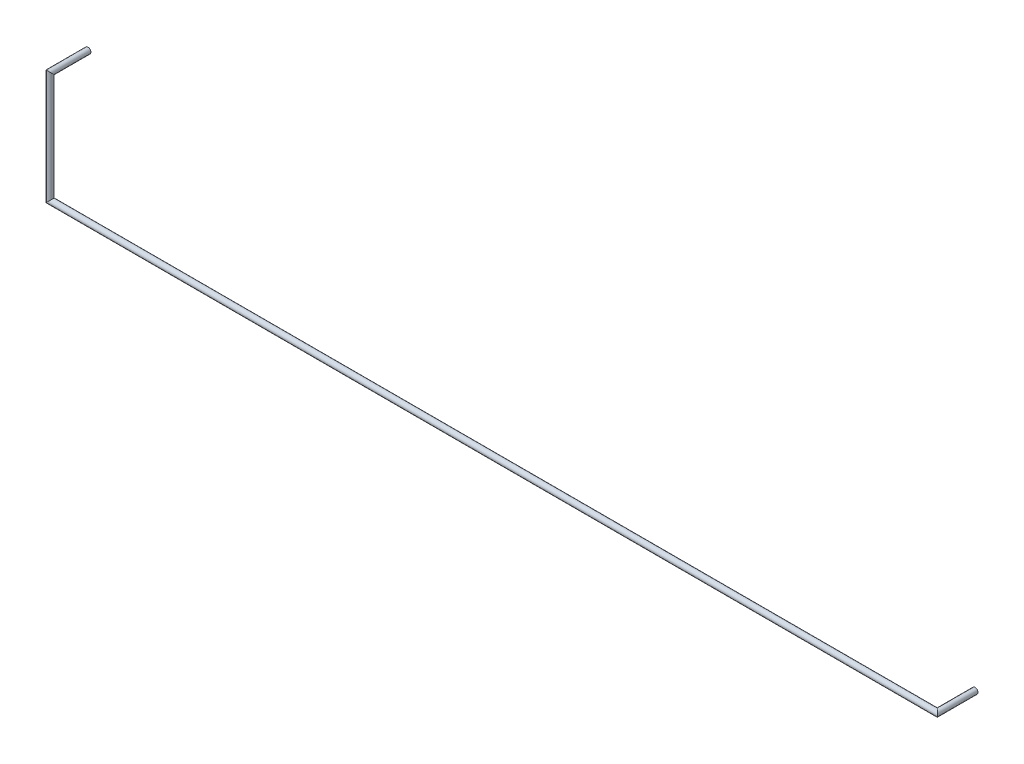
from build123d import *

# Parameters (mm, degrees)
SWEEP1_PROFILE_R = 0.2


with BuildPart() as part:
    # Sweep1: sweep along a curve in space
    with BuildLine() as sweep1_path:
        Line((0, 0, 0), (0, 0, 2.6))
        Line((0, 0, 2.6), (0, -7.62, 2.6))
        Line((0, -7.62, 2.6), (60.96, -7.62, 2.6))
        Line((60.96, -7.62, 2.6), (60.96, -7.62, 0))
    # Sweep1 profile (on start of the path) → Sweep1 (sweep)
    with BuildSketch(Plane.XY):
        Circle(SWEEP1_PROFILE_R)
    sweep(path=sweep1_path.line, transition=Transition.RIGHT)


solid = part.part
